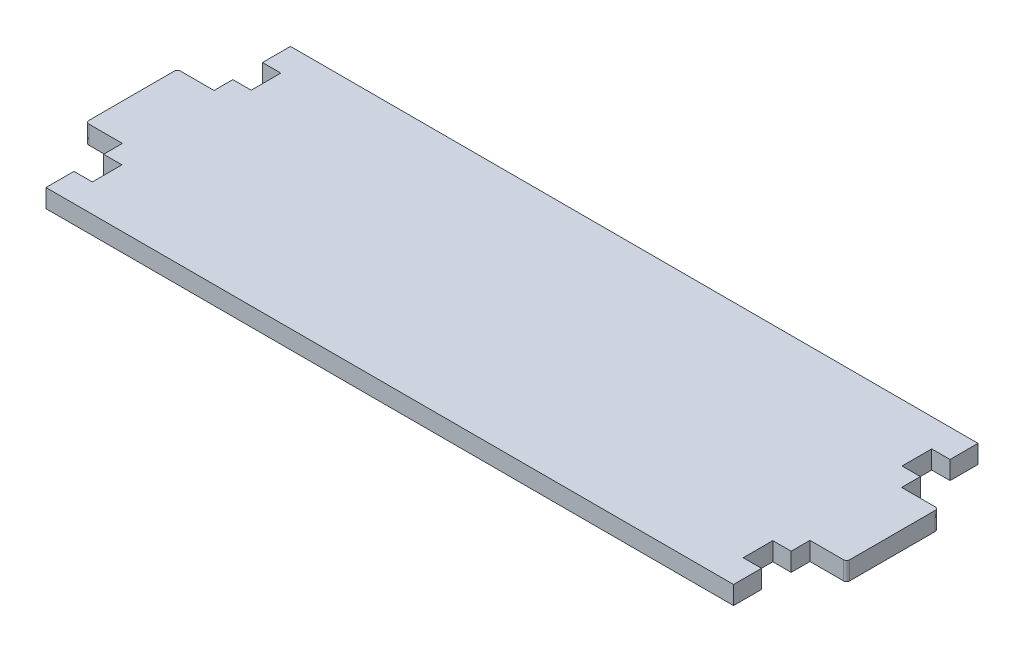
from build123d import *

# Parameters (mm, degrees)
EXTRUDE_1_DEPTH = 3
FILLET_1_R      = 0.5


with BuildPart() as part:
    # Эскиз1 → Бобышка-Вытянуть1 (new body)
    with BuildSketch(Plane(origin=(0, 0, 0), x_dir=(1, 0, 0), z_dir=(0, 1, 0))):
        Polygon((56.25, 20), (-56.25, 20), (-56.25, 15.425), (-53.25, 15.425), (-53.25, 10.575), (-56.25, 10.575), (-56.25, 7.5), (-62.25, 7.5), (-62.25, -7.5), (-56.25, -7.5), (-56.25, -10.575), (-53.25, -10.575), (-53.25, -15.425), (-56.25, -15.425), (-56.25, -20), (56.25, -20), (56.25, -15.425), (53.25, -15.425), (53.25, -10.575), (56.25, -10.575), (56.25, -7.5), (62.25, -7.5), (62.25, 7.5), (56.25, 7.5), (56.25, 10.575), (53.25, 10.575), (53.25, 15.425), (56.25, 15.425), align=None)
    extrude(amount=EXTRUDE_1_DEPTH)

    # Скругление1
    fillet_1_edges = [part.edges().sort_by_distance(p)[0] for p in [
        (-62.25, 1.5, 7.5),
        (-62.25, 1.5, -7.5),
        (62.25, 1.5, -7.5),
        (62.25, 1.5, 7.5),
    ]]
    fillet(fillet_1_edges, radius=FILLET_1_R)


solid = part.part
